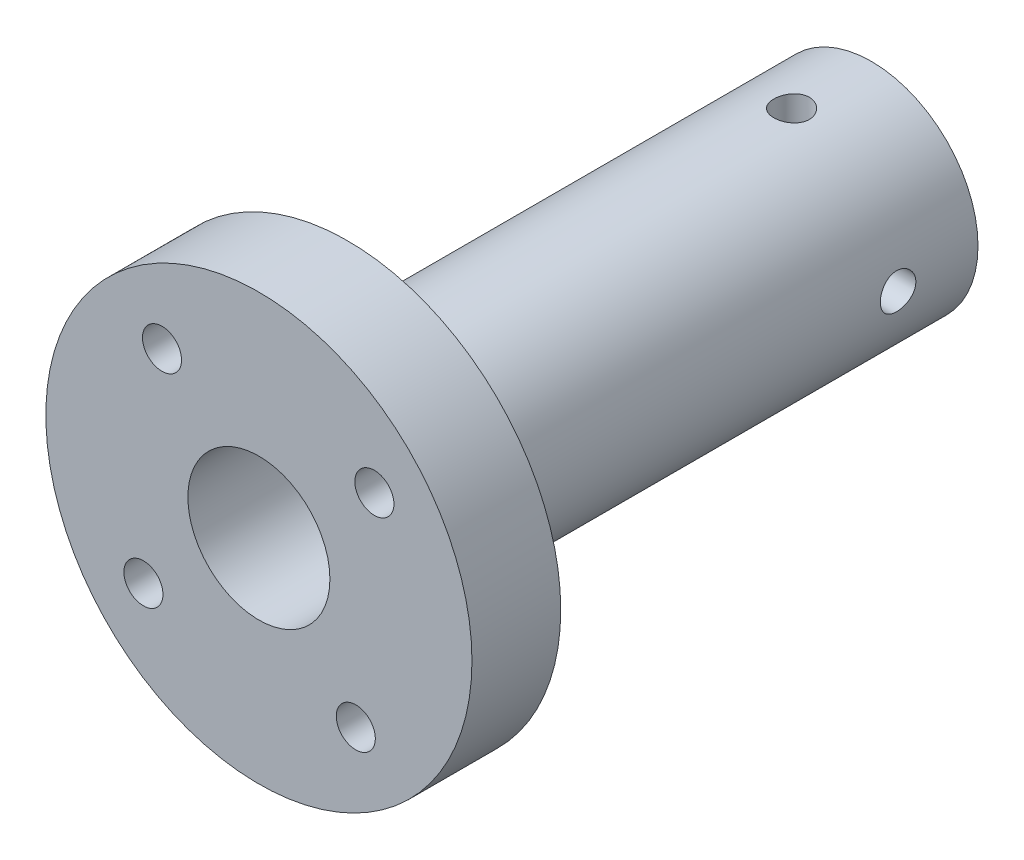
from build123d import *

# Parameters (mm, degrees)
SKIZZE1_R                            = 12.5
AUFSATZ_LINEAR_AUSTRAGEN1_DEPTH      = 40
SCHNITT_LINEAR_START                 = 30
SKIZZE4_R                            = 15
SKIZZE4_R_2                          = 12
SCHNITT_LINEAR_AUSTRAGEN1_DEPTH      = 20
SKIZZE5_R                            = 1.1
SCHNITT_LINEAR_AUSTRAGEN2_DEPTH      = 20
SKIZZE6_R                            = 1
SCHNITT_LINEAR_AUSTRAGEN3_DEPTH      = 10
SKIZZE8_W                            = 5.5
SKIZZE8_H                            = 25
SCHNITT_LINEAR_AUSTRAGEN5_DEPTH      = 13.5
SCHNITT_LINEAR_AUSTRAGEN5_DEPTH_BACK = 13.5
SKIZZE9_R                            = 1
SCHNITT_LINEAR_AUSTRAGEN6_DEPTH      = 13
SCHNITT_LINEAR_AUSTRAGEN6_DEPTH_BACK = 13
SKIZZE11_R                           = 1
SCHNITT_LINEAR_AUSTRAGEN7_DEPTH      = 13
SCHNITT_LINEAR_AUSTRAGEN7_DEPTH_BACK = 13


with BuildPart() as part:
    # Skizze1 → Aufsatz-Linear austragen1 (new body)
    with BuildSketch(Plane.XY):
        Circle(SKIZZE1_R)
    extrude(amount=AUFSATZ_LINEAR_AUSTRAGEN1_DEPTH)

    # Skizze2 → Schnitt-Rotation3 (revolve, cut)
    with BuildSketch(Plane(origin=(0, 0, 0), x_dir=(0, 0, -1), z_dir=(1, 0, 0))):
        Polygon((-35, -12.5), (-35, -6), (-5, -6), (-5, -12.5), (-33.974333956, -17.5), align=None)
    revolve(axis=Axis((0, 0, 40), (0, 0, -1)), mode=Mode.SUBTRACT)

    # Skizze4 → Schnitt-Linear austragen1 (cut)
    with BuildSketch(Plane.XY.offset(SCHNITT_LINEAR_START)):
        Circle(SKIZZE4_R)
        Circle(SKIZZE4_R_2, mode=Mode.SUBTRACT)
    extrude(amount=SCHNITT_LINEAR_AUSTRAGEN1_DEPTH, mode=Mode.SUBTRACT)

    # Skizze5 → Schnitt-Linear austragen2 (cut)
    with BuildSketch(Plane.XY.offset(40)):
        with Locations((-5.457266806, 6.503717322)):
            Circle(SKIZZE5_R)
        with Locations((6.503717322, 5.457266806)):
            Circle(SKIZZE5_R)
        with Locations((5.457266806, -6.503717322)):
            Circle(SKIZZE5_R)
        with Locations((-6.503717322, -5.457266806)):
            Circle(SKIZZE5_R)
    extrude(amount=-SCHNITT_LINEAR_AUSTRAGEN2_DEPTH, mode=Mode.SUBTRACT)

    # Skizze6 → Schnitt-Linear austragen3 (cut)
    with BuildSketch(Plane(origin=(0, 0, 0), x_dir=(-1, 0, 0), z_dir=(0, 0, -1))):
        with Locations((-2.25, 0)):
            Circle(SKIZZE6_R)
        with Locations((0, 2.25)):
            Circle(SKIZZE6_R)
        with Locations((2.25, 0)):
            Circle(SKIZZE6_R)
        with Locations((0, -2.25)):
            Circle(SKIZZE6_R)
    extrude(amount=-SCHNITT_LINEAR_AUSTRAGEN3_DEPTH, mode=Mode.SUBTRACT)

    # Skizze7 → Schnitt-Rotation4 (revolve, cut)
    with BuildSketch(Plane(origin=(0, 0, 0), x_dir=(0, 0, -1), z_dir=(1, 0, 0))):
        Polygon((-5.069914244, 0), (-35.074978214, 0), (-40, 0), (-42.313201415, 0), (-42.313201415, -4), (-40, -4), (-35, -4), (-5, -4), align=None)
    revolve(axis=Axis((0, 0, 40), (0, 0, -1)), mode=Mode.SUBTRACT)

    # Skizze8 → Schnitt-Linear austragen5 (cut, two sides)
    with BuildSketch(Plane(origin=(0, 0, 0), x_dir=(0, 0, -1), z_dir=(1, 0, 0))) as schnitt_linear_austragen5_sk:
        with Locations((-2.75, 0)):
            Rectangle(SKIZZE8_W, SKIZZE8_H)
    extrude(amount=SCHNITT_LINEAR_AUSTRAGEN5_DEPTH, mode=Mode.SUBTRACT)
    extrude(schnitt_linear_austragen5_sk.sketch, amount=-SCHNITT_LINEAR_AUSTRAGEN5_DEPTH_BACK, mode=Mode.SUBTRACT)

    # Skizze9 → Schnitt-Linear austragen6 (cut, two sides)
    with BuildSketch(Plane(origin=(0, 0, 0), x_dir=(0, 0, -1), z_dir=(1, 0, 0))) as schnitt_linear_austragen6_sk:
        with Locations((-10, 0)):
            Circle(SKIZZE9_R)
    extrude(amount=SCHNITT_LINEAR_AUSTRAGEN6_DEPTH, mode=Mode.SUBTRACT)
    extrude(schnitt_linear_austragen6_sk.sketch, amount=-SCHNITT_LINEAR_AUSTRAGEN6_DEPTH_BACK, mode=Mode.SUBTRACT)

    # Skizze11 → Schnitt-Linear austragen7 (cut, two sides)
    with BuildSketch(Plane(origin=(0, 0, 0), x_dir=(1, 0, 0), z_dir=(0, 1, 0))) as schnitt_linear_austragen7_sk:
        with Locations((0, -10)):
            Circle(SKIZZE11_R)
    extrude(amount=SCHNITT_LINEAR_AUSTRAGEN7_DEPTH, mode=Mode.SUBTRACT)
    extrude(schnitt_linear_austragen7_sk.sketch, amount=-SCHNITT_LINEAR_AUSTRAGEN7_DEPTH_BACK, mode=Mode.SUBTRACT)


solid = part.part
